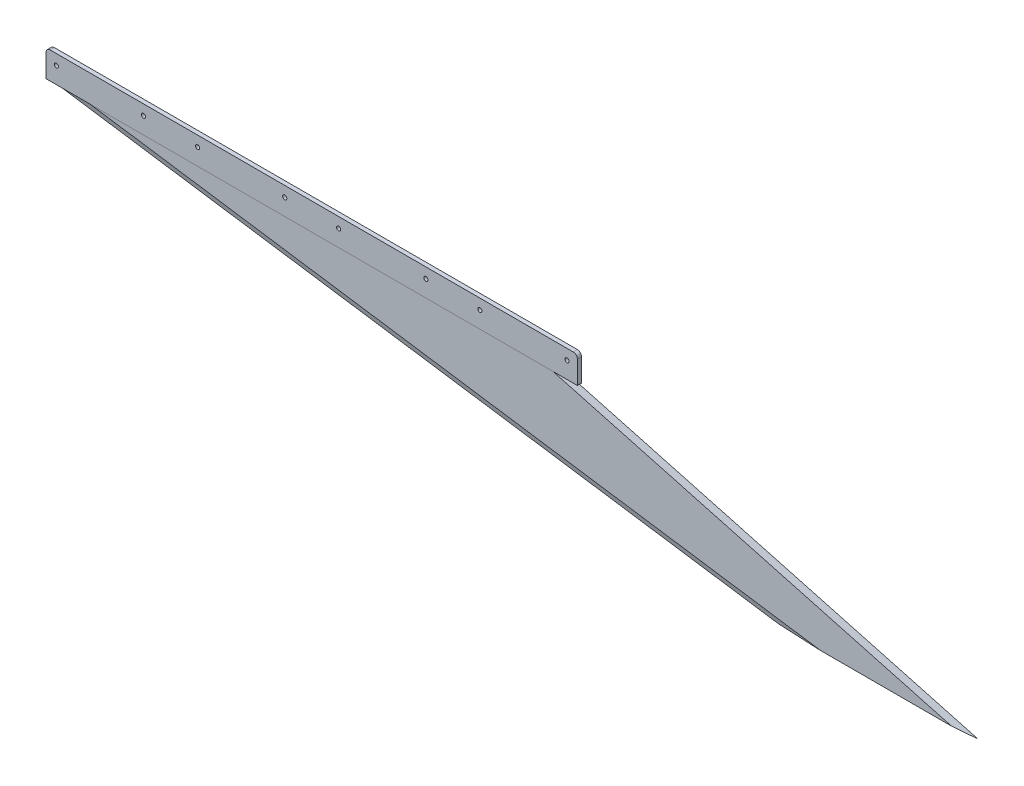
from build123d import *

# Parameters (mm, degrees)
BOSS_EXTRUDE1_DEPTH = 6.35
CUT_EXTRUDE5_DEPTH  = 1432.25665609
CUT_EXTRUDE6_DEPTH  = 721.614
SKETCH19_W          = 812.8
SKETCH19_H          = 6.35
BOSS_EXTRUDE8_DEPTH = 3.175
SKETCH20_W          = 812.8
SKETCH20_H          = 6.35
BOSS_EXTRUDE9_DEPTH = 38.1
FILLET1_R           = 6.35
FILLET2_R           = 6.35
CUT_EXTRUDE7_REACH  = 8.35
SKETCH22_R          = 3.175


with BuildPart() as part:
    # Sketch1 → Boss-Extrude1 (new body)
    with BuildSketch(Plane.XY):
        Polygon((-812.8, 0), (0, 0), (609.6, -165.1), (304.8, -165.1), align=None)
    extrude(amount=BOSS_EXTRUDE1_DEPTH)

    # Sketch17 → Cut-Extrude5 (cut, through all)
    with BuildSketch(Plane(origin=(-795.440818906, 117.508302793, 0), x_dir=(0, 0, -1), z_dir=(-0.989263736, 0.146141234, 0))):
        Polygon((-3.175, 118.7835948), (-6.35, 109.011949569), (-6.35, 209.992544036), (0, 209.992544036), (0, 109.011949569), align=None)
    extrude(amount=-CUT_EXTRUDE5_DEPTH, mode=Mode.SUBTRACT)

    # Sketch18 → Cut-Extrude6 (cut)
    with BuildSketch(Plane(origin=(609.6, -165.1, 0), x_dir=(0, 0, -1), z_dir=(0.965226372, -0.261415476, 0))):
        Polygon((-3.175, 0), (-6.35, -9.771645231), (-6.35, 0.882856688), (0, 0.882856688), (0, -9.771645231), align=None)
    extrude(amount=-CUT_EXTRUDE6_DEPTH, mode=Mode.SUBTRACT)

    # Sketch19 → Boss-Extrude8 (add)
    with BuildSketch(Plane(origin=(0, 0, 0), x_dir=(1, 0, 0), z_dir=(0, 1, 0))):
        with Locations((-406.4, -3.175)):
            Rectangle(SKETCH19_W, SKETCH19_H)
    extrude(amount=BOSS_EXTRUDE8_DEPTH)

    # Sketch20 → Boss-Extrude9 (add)
    with BuildSketch(Plane(origin=(0, 3.175, 0), x_dir=(1, 0, 0), z_dir=(0, 1, 0))):
        with Locations((-406.4, -3.175)):
            Rectangle(SKETCH20_W, SKETCH20_H)
    extrude(amount=BOSS_EXTRUDE9_DEPTH)

    # Fillet1
    fillet1_edges = [part.edges().sort_by_distance(p)[0] for p in [
        (0, 41.275, 3.175),
    ]]
    fillet(fillet1_edges, radius=FILLET1_R)

    # Fillet2
    fillet2_edges = [part.edges().sort_by_distance(p)[0] for p in [
        (-812.8, 41.275, 3.175),
    ]]
    fillet(fillet2_edges, radius=FILLET2_R)

    # Sketch22 → Cut-Extrude7 (cut, up to next)
    with BuildSketch(Plane(origin=(0, 0, 0), x_dir=(-1, 0, 0), z_dir=(0, 0, -1)), mode=Mode.PRIVATE) as cut_extrude7_sk1:
        with Locations((149.225, 25.4)):
            Circle(SKETCH22_R)
    cut_extrude7_tool1 = extrude(cut_extrude7_sk1.sketch, amount=-CUT_EXTRUDE7_REACH, mode=Mode.PRIVATE) & part.part
    add(cut_extrude7_tool1.solids().sort_by_distance((-149.225, 25.4, 0))[0], mode=Mode.SUBTRACT)
    # Sketch22 → Cut-Extrude7 (cut, up to next)
    with BuildSketch(Plane(origin=(0, 0, 0), x_dir=(-1, 0, 0), z_dir=(0, 0, -1)), mode=Mode.PRIVATE) as cut_extrude7_sk2:
        with Locations((796.925, 25.4)):
            Circle(SKETCH22_R)
    cut_extrude7_tool2 = extrude(cut_extrude7_sk2.sketch, amount=-CUT_EXTRUDE7_REACH, mode=Mode.PRIVATE) & part.part
    add(cut_extrude7_tool2.solids().sort_by_distance((-796.925, 25.4, 0))[0], mode=Mode.SUBTRACT)
    # Sketch22 → Cut-Extrude7 (cut, up to next)
    with BuildSketch(Plane(origin=(0, 0, 0), x_dir=(-1, 0, 0), z_dir=(0, 0, -1)), mode=Mode.PRIVATE) as cut_extrude7_sk3:
        with Locations((663.575, 25.4)):
            Circle(SKETCH22_R)
    cut_extrude7_tool3 = extrude(cut_extrude7_sk3.sketch, amount=-CUT_EXTRUDE7_REACH, mode=Mode.PRIVATE) & part.part
    add(cut_extrude7_tool3.solids().sort_by_distance((-663.575, 25.4, 0))[0], mode=Mode.SUBTRACT)
    # Sketch22 → Cut-Extrude7 (cut, up to next)
    with BuildSketch(Plane(origin=(0, 0, 0), x_dir=(-1, 0, 0), z_dir=(0, 0, -1)), mode=Mode.PRIVATE) as cut_extrude7_sk4:
        with Locations((581.025, 25.4)):
            Circle(SKETCH22_R)
    cut_extrude7_tool4 = extrude(cut_extrude7_sk4.sketch, amount=-CUT_EXTRUDE7_REACH, mode=Mode.PRIVATE) & part.part
    add(cut_extrude7_tool4.solids().sort_by_distance((-581.025, 25.4, 0))[0], mode=Mode.SUBTRACT)
    # Sketch22 → Cut-Extrude7 (cut, up to next)
    with BuildSketch(Plane(origin=(0, 0, 0), x_dir=(-1, 0, 0), z_dir=(0, 0, -1)), mode=Mode.PRIVATE) as cut_extrude7_sk5:
        with Locations((447.675, 25.4)):
            Circle(SKETCH22_R)
    cut_extrude7_tool5 = extrude(cut_extrude7_sk5.sketch, amount=-CUT_EXTRUDE7_REACH, mode=Mode.PRIVATE) & part.part
    add(cut_extrude7_tool5.solids().sort_by_distance((-447.675, 25.4, 0))[0], mode=Mode.SUBTRACT)
    # Sketch22 → Cut-Extrude7 (cut, up to next)
    with BuildSketch(Plane(origin=(0, 0, 0), x_dir=(-1, 0, 0), z_dir=(0, 0, -1)), mode=Mode.PRIVATE) as cut_extrude7_sk6:
        with Locations((365.125, 25.4)):
            Circle(SKETCH22_R)
    cut_extrude7_tool6 = extrude(cut_extrude7_sk6.sketch, amount=-CUT_EXTRUDE7_REACH, mode=Mode.PRIVATE) & part.part
    add(cut_extrude7_tool6.solids().sort_by_distance((-365.125, 25.4, 0))[0], mode=Mode.SUBTRACT)
    # Sketch22 → Cut-Extrude7 (cut, up to next)
    with BuildSketch(Plane(origin=(0, 0, 0), x_dir=(-1, 0, 0), z_dir=(0, 0, -1)), mode=Mode.PRIVATE) as cut_extrude7_sk7:
        with Locations((231.775, 25.4)):
            Circle(SKETCH22_R)
    cut_extrude7_tool7 = extrude(cut_extrude7_sk7.sketch, amount=-CUT_EXTRUDE7_REACH, mode=Mode.PRIVATE) & part.part
    add(cut_extrude7_tool7.solids().sort_by_distance((-231.775, 25.4, 0))[0], mode=Mode.SUBTRACT)
    # Sketch22 → Cut-Extrude7 (cut, up to next)
    with BuildSketch(Plane(origin=(0, 0, 0), x_dir=(-1, 0, 0), z_dir=(0, 0, -1)), mode=Mode.PRIVATE) as cut_extrude7_sk8:
        with Locations((15.875, 25.4)):
            Circle(SKETCH22_R)
    cut_extrude7_tool8 = extrude(cut_extrude7_sk8.sketch, amount=-CUT_EXTRUDE7_REACH, mode=Mode.PRIVATE) & part.part
    add(cut_extrude7_tool8.solids().sort_by_distance((-15.875, 25.4, 0))[0], mode=Mode.SUBTRACT)


solid = part.part
